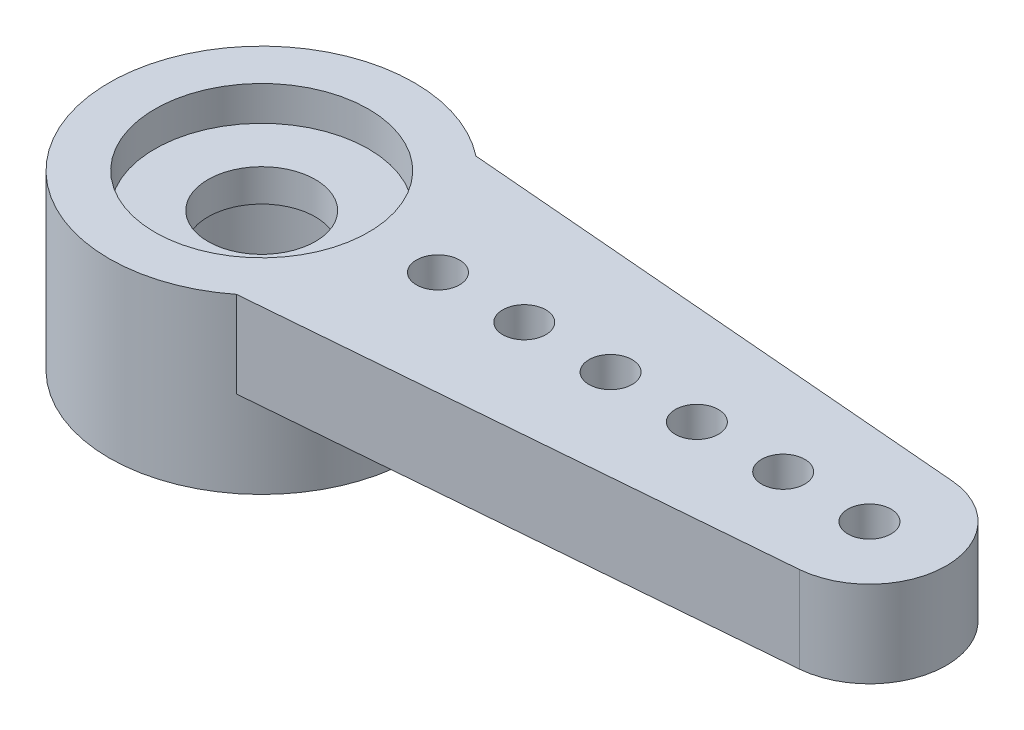
from build123d import *

# Parameters (mm, degrees)
BOSS_EXTRUDE1_DEPTH = 2


with BuildPart() as part:
    # Sketch2 → Revolve1 (revolve)
    with BuildSketch(Plane.XY):
        Polygon((2.475, 2), (2.475, 1.2), (1.245, 1.2), (1.245, 0.45), (2.375, 0.45), (2.375, -2), (3.535, -2), (3.535, 2), align=None)
    revolve(axis=Axis((0, 55, 0), (0, -1, 0)))

    # Sketch3 → Boss-Extrude1 (add)
    with BuildSketch(Plane(origin=(0, 0, 0), x_dir=(1, 0, 0), z_dir=(0, 1, 0))):
        with BuildLine():
            ThreePointArc((3.535, 0), (3.180996027, -1.541910917), (2.189885842, -2.775))
            Line((2.189885842, -2.775), (14.232465575, -1.773881029))
            ThreePointArc((14.232465575, -1.773881029), (13.044016702, -1.443867644), (12.3554, -0.420575606))
            ThreePointArc((12.3554, -0.420575606), (11.845417029, -0.438862165), (11.585, 0))
            Line((11.585, 0), (10.585, 0))
            ThreePointArc((10.585, 0), (10.085, -0.5), (9.585, 0))
            Line((9.585, 0), (8.585, 0))
            ThreePointArc((8.585, 0), (8.085, -0.5), (7.585, 0))
            Line((7.585, 0), (6.585, 0))
            ThreePointArc((6.585, 0), (6.085, -0.5), (5.585, 0))
            Line((5.585, 0), (4.585, 0))
            ThreePointArc((4.585, 0), (4.085, -0.5), (3.585, 0))
            Line((3.585, 0), (3.535, 0))
        make_face()
        with BuildLine():
            ThreePointArc((12.3554, -0.420575606), (13.044016702, -1.443867644), (14.232465575, -1.773881029))
            ThreePointArc((14.232465575, -1.773881029), (15.394749733, -1.205386095), (15.865, 0))
            Line((15.865, 0), (14.585, 0))
            ThreePointArc((14.585, 0), (14.085, -0.5), (13.585, 0))
            Line((13.585, 0), (12.585, 0))
            ThreePointArc((12.585, 0), (12.523862165, -0.239582971), (12.3554, -0.420575606))
        make_face()
    boss_extrude1 = extrude(amount=BOSS_EXTRUDE1_DEPTH)

    # Mirror1: Boss-Extrude1 across plane
    add(boss_extrude1.mirror(Plane(origin=(0, 15.95383002, 0), x_dir=(1, 0, 0), z_dir=(0, 0, -1))))


solid = part.part
